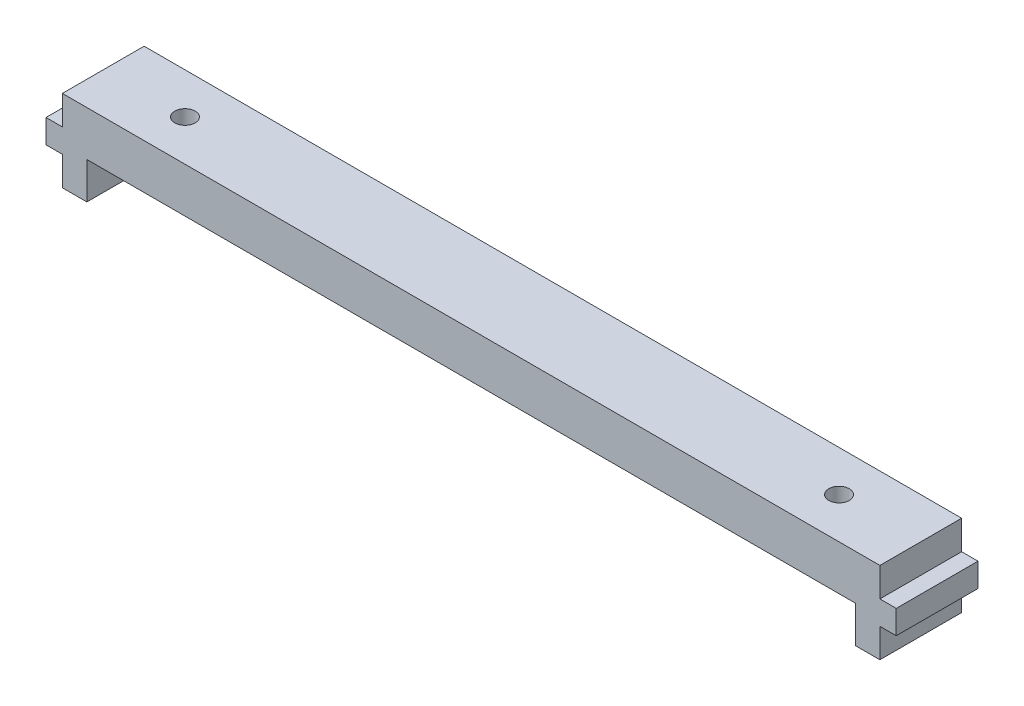
from build123d import *

# Parameters (mm, degrees)
MAINLEFT_DEPTH     = 10
SKETCH3_R          = 1.25
CUT_EXTRUDE2_DEPTH = 6.5


with BuildPart() as part:
    # Sketch1 → MainLeft (new body)
    with BuildSketch(Plane.XY):
        Polygon((-50, 5.5), (-50, 1.95), (-52, 1.95), (-52, -0.95), (-50, -0.95), (-50, -4.5), (-47, -4.5), (-47, 0), (0, 0), (0, 5.5), align=None)
    mainleft = extrude(amount=MAINLEFT_DEPTH)

    # Sketch3 → Cut-Extrude2 (cut, through all)
    with BuildSketch(Plane.XZ):
        with Locations((-40, 5)):
            Circle(SKETCH3_R)
    cut_extrude2 = extrude(amount=-CUT_EXTRUDE2_DEPTH, mode=Mode.SUBTRACT)

    # Mirror1: MainLeft, Cut-Extrude2 across plane
    add(mainleft.mirror(Plane(origin=(0, 0, 0), x_dir=(0, 0, 1), z_dir=(1, 0, 0))))
    add(cut_extrude2.mirror(Plane(origin=(0, 0, 0), x_dir=(0, 0, 1), z_dir=(1, 0, 0))), mode=Mode.SUBTRACT)


solid = part.part
